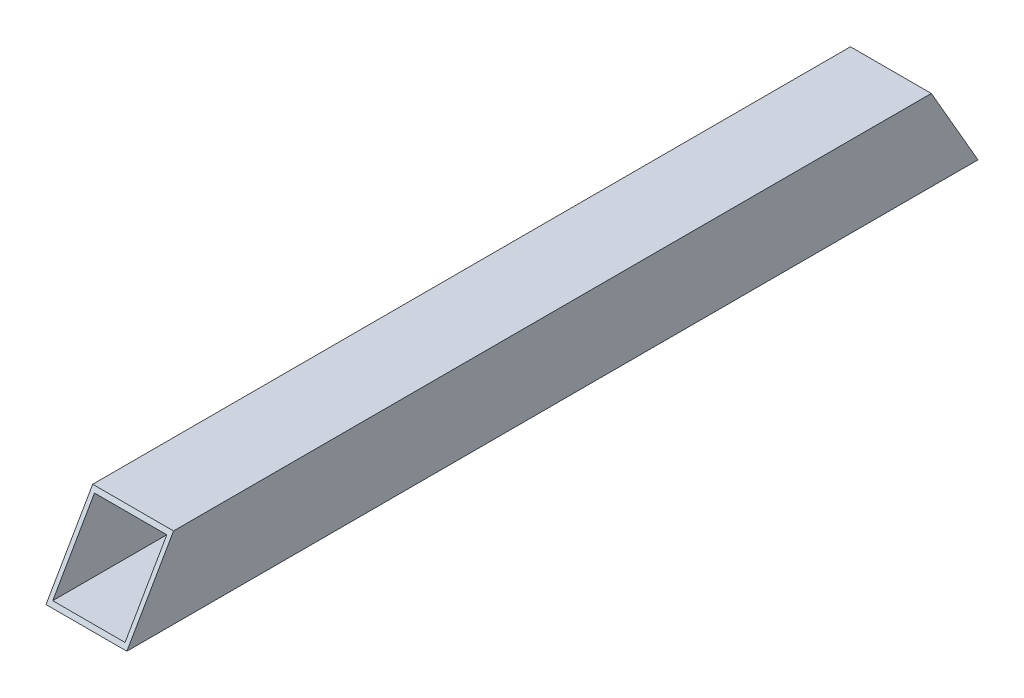
from build123d import *

# Parameters (mm, degrees)
SKETCH1_W               = 19
SKETCH1_H               = 19
SKETCH1_W_2             = 17
SKETCH1_H_2             = 17
BOSS_EXTRUDE1_DEPTH     = 200
CUT_EXTRUDE1_DEPTH      = 1
CUT_EXTRUDE1_DEPTH_BACK = 20
CUT_EXTRUDE2_DEPTH      = 1
CUT_EXTRUDE2_DEPTH_BACK = 20


with BuildPart() as part:
    # Sketch1 → Boss-Extrude1 (new body)
    with BuildSketch(Plane.XY):
        Rectangle(SKETCH1_W, SKETCH1_H)
        Rectangle(SKETCH1_W_2, SKETCH1_H_2, mode=Mode.SUBTRACT)
    extrude(amount=BOSS_EXTRUDE1_DEPTH)

    # Sketch2 → Cut-Extrude1 (cut, two sides)
    with BuildSketch(Plane(origin=(9.5, 0, 0), x_dir=(0, 0, -1), z_dir=(1, 0, 0))) as cut_extrude1_sk:
        Polygon((-405.900472872, -366.130080316), (-200, -9.5), (-189.030344885, 9.5), (16.870127986, 366.130080316), (-696.390032646, 777.931026059), (-1119.160633503, 45.670865427), align=None)
    extrude(amount=CUT_EXTRUDE1_DEPTH, mode=Mode.SUBTRACT)
    extrude(cut_extrude1_sk.sketch, amount=-CUT_EXTRUDE1_DEPTH_BACK, mode=Mode.SUBTRACT)

    # Sketch3 → Cut-Extrude2 (cut, two sides)
    with BuildSketch(Plane(origin=(9.5, 0, 0), x_dir=(0, 0, -1), z_dir=(1, 0, 0))) as cut_extrude2_sk:
        Polygon((205.900472872, -366.130080316), (0, -9.5), (-10.969655115, 9.5), (-216.870127986, 366.130080316), (496.390032646, 777.931026059), (919.160633503, 45.670865427), align=None)
    extrude(amount=CUT_EXTRUDE2_DEPTH, mode=Mode.SUBTRACT)
    extrude(cut_extrude2_sk.sketch, amount=-CUT_EXTRUDE2_DEPTH_BACK, mode=Mode.SUBTRACT)


solid = part.part
